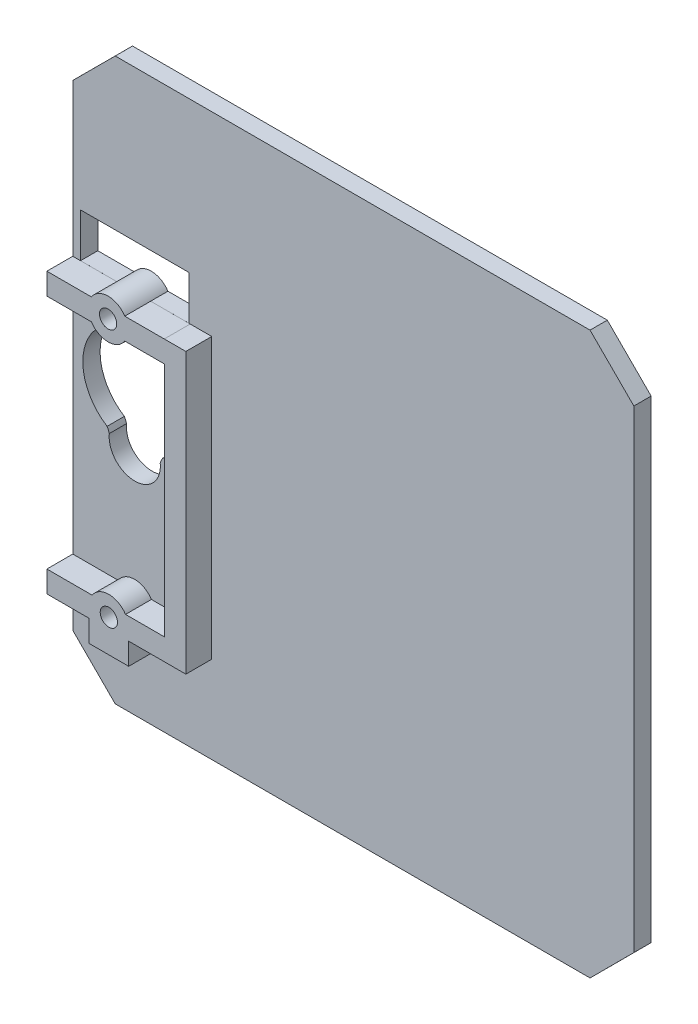
from build123d import *

# Parameters (mm, degrees)
BOSS_EXTRUDE3_DEPTH = 2
SKETCH7_R           = 1
SKETCH7_W           = 2.5
SKETCH7_H           = 2.5
BOSS_EXTRUDE5_DEPTH = 3


with BuildPart() as part:
    # Sketch2 → Boss-Extrude3 (new body)
    with BuildSketch(Plane.XY):
        Polygon((62.078732257, 67), (7.070378023, 67), (2.153513577, 62.087886246), (2.153513577, 6.916864445), (7.070378023, 2), (62.078732257, 2), (67.153513577, 7.083274694), (67.153513577, 61.921636784), align=None)
        with BuildLine():
            ThreePointArc((12.561398281, 29.386897281), (12.405099811, 29.087669445), (12.28230409, 28.773205265))
            ThreePointArc((12.28230409, 28.773205265), (9.332354964, 25.48092154), (6.384978263, 28.775508397))
            ThreePointArc((6.384978263, 28.775508397), (6.272687262, 29.080787813), (6.128559615, 29.372390302))
            ThreePointArc((6.128559615, 29.372390302), (9.319946418, 40.479834047), (12.561398281, 29.386897281))
        make_face(mode=Mode.SUBTRACT)
        with BuildLine():
            Line((7.315683042, 44.45), (3.053513577, 44.45))
            Line((3.053513577, 44.45), (3.053513577, 49.55))
            Line((3.053513577, 49.55), (15.603513577, 49.55))
            Line((15.603513577, 49.55), (15.603513577, 44.45))
            Line((15.603513577, 44.45), (11.175073004, 44.45))
            ThreePointArc((11.175073004, 44.45), (9.245378023, 45.49849), (7.315683042, 44.45))
        make_face(mode=Mode.SUBTRACT)
    extrude(amount=BOSS_EXTRUDE3_DEPTH)

    # Sketch7 → Boss-Extrude5 (add)
    with BuildSketch(Plane.XY.offset(2)):
        with BuildLine():
            Line((15.753513577, 14.57), (11.264187035, 14.57))
            ThreePointArc((11.264187035, 14.57), (9.333513577, 15.62), (7.40284012, 14.57))
            Line((7.40284012, 14.57), (2.153513577, 14.57))
            Line((2.153513577, 14.57), (2.153513577, 12.07))
            Line((2.153513577, 12.07), (7.033513577, 12.07))
            Line((7.033513577, 12.07), (7.40284012, 12.07))
            ThreePointArc((7.40284012, 12.07), (9.333513577, 11.02), (11.264187035, 12.07))
            Line((11.264187035, 12.07), (11.633513577, 12.07))
            Line((11.633513577, 12.07), (15.753513577, 12.07))
            Line((15.753513577, 12.07), (15.753513577, 14.57))
        make_face()
        with Locations((9.333513577, 13.32)):
            Circle(SKETCH7_R, mode=Mode.SUBTRACT)
        with BuildLine():
            Line((11.633513577, 9.547776159), (11.633513577, 12.07))
            Line((11.633513577, 12.07), (11.264187035, 12.07))
            ThreePointArc((11.264187035, 12.07), (9.333513577, 11.02), (7.40284012, 12.07))
            Line((7.40284012, 12.07), (7.033513577, 12.07))
            Line((7.033513577, 12.07), (7.033513577, 9.547776159))
            Line((7.033513577, 9.547776159), (11.633513577, 9.547776159))
        make_face()
        with Locations((17.003513577, 13.32)):
            Rectangle(SKETCH7_W, SKETCH7_H)
        with BuildLine():
            Line((15.753513577, 16.534568208), (15.753513577, 14.57))
            Line((15.753513577, 14.57), (18.253513577, 14.57))
            Line((18.253513577, 14.57), (18.253513577, 16.534568208))
            Line((18.253513577, 16.534568208), (18.253513577, 44.45))
            Line((18.253513577, 44.45), (15.753513577, 44.45))
            Line((15.753513577, 44.45), (15.753513577, 44.44849))
            Line((15.753513577, 44.44849), (11.17605148, 44.44849))
            ThreePointArc((11.17605148, 44.44849), (11.17556239, 44.449245096), (11.175073004, 44.45))
            ThreePointArc((11.175073004, 44.45), (10.343450652, 45.219439406), (9.245378023, 45.49849))
            ThreePointArc((9.245378023, 45.49849), (8.147305393, 45.219439406), (7.315683042, 44.45))
            ThreePointArc((7.315683042, 44.45), (7.315193656, 44.449245096), (7.314704565, 44.44849))
            Line((7.314704565, 44.44849), (2.153513577, 44.44849))
            Line((2.153513577, 44.44849), (2.153513577, 41.94849))
            Line((2.153513577, 41.94849), (7.314704565, 41.94849))
            ThreePointArc((7.314704565, 41.94849), (9.245378023, 40.89849), (11.17605148, 41.94849))
            Line((11.17605148, 41.94849), (15.753513577, 41.94849))
            Line((15.753513577, 41.94849), (15.753513577, 16.534568208))
        make_face()
        with Locations((9.245378023, 43.19849)):
            Circle(SKETCH7_R, mode=Mode.SUBTRACT)
    extrude(amount=BOSS_EXTRUDE5_DEPTH)


solid = part.part
